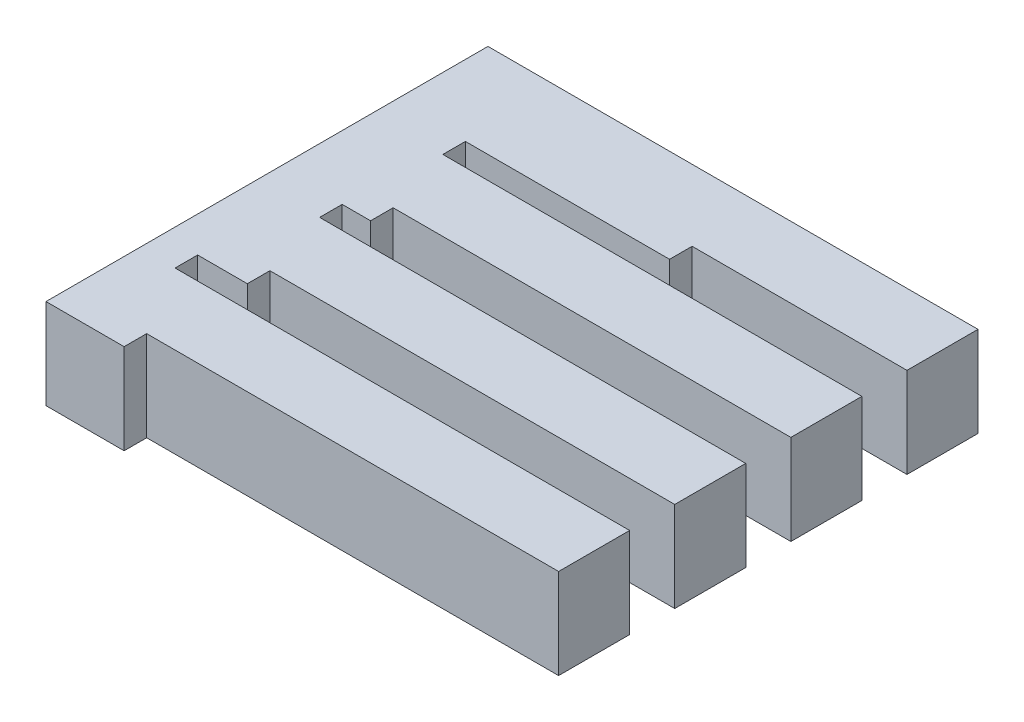
from build123d import *

# Parameters (mm, degrees)
BOSS_EXTRUDE1_DEPTH = 6.35


with BuildPart() as part:
    # Sketch1 → Boss-Extrude1 (new body, symmetric)
    with BuildSketch(Plane(origin=(0, 0, 0), x_dir=(1, 0, 0), z_dir=(0, 1, 0))):
        Polygon((-34.5, -31.1125), (-23.5, -31.1125), (-23.5, -27.9375), (34.5, -27.9375), (34.5, -17.9375), (-29.5, -17.9375), (-29.5, -14.7625), (-22.5, -14.7625), (-22.5, -11.5875), (34.5, -11.5875), (34.5, -1.5875), (-25.5, -1.5875), (-25.5, 1.5875), (-21.5, 1.5875), (-21.5, 4.7625), (34.5, 4.7625), (34.5, 14.7625), (-24.5, 14.7625), (-24.5, 17.9375), (4.24574702, 17.9375), (4.24574702, 21.1125), (34.5, 21.1125), (34.5, 31.1125), (-34.5, 31.1125), align=None)
    extrude(amount=BOSS_EXTRUDE1_DEPTH, both=True)


solid = part.part
